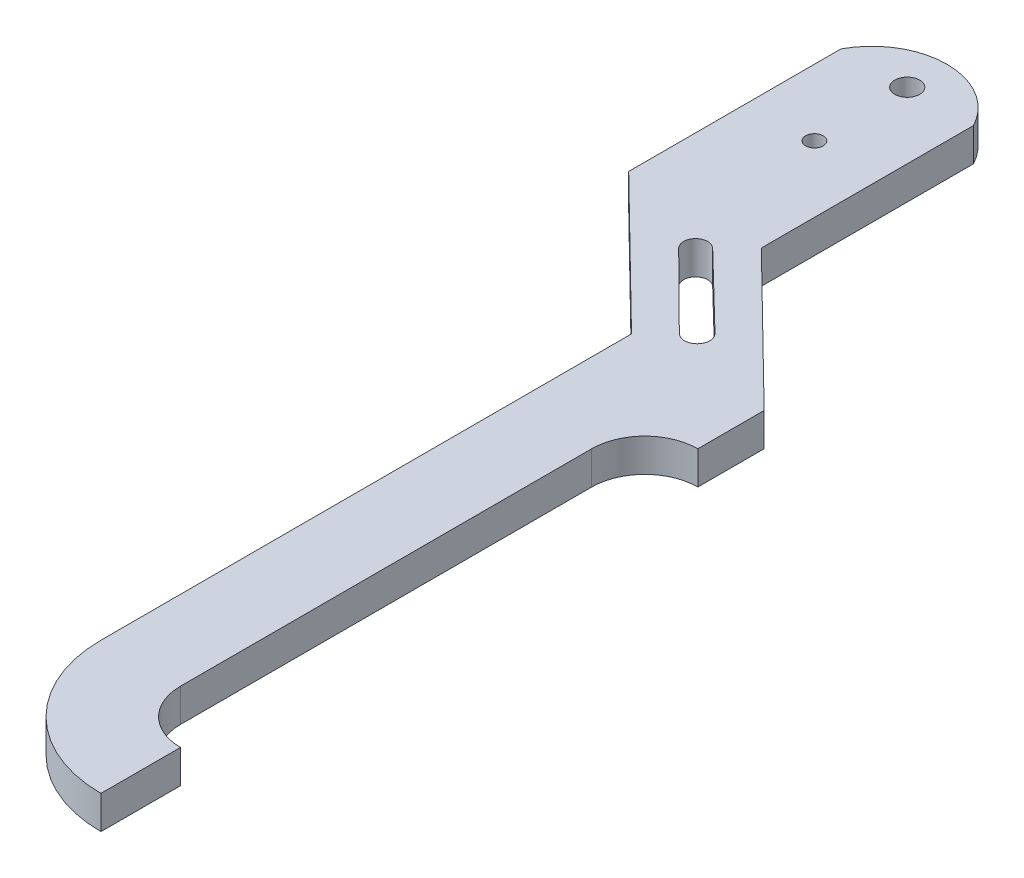
from build123d import *

# Parameters (mm, degrees)
SKETCH1_R           = 0.840105
SKETCH1_R_2         = 1.190625
BOSS_EXTRUDE1_DEPTH = 3.175


with BuildPart() as part:
    # Sketch1 → Boss-Extrude1 (new body)
    with BuildSketch(Plane(origin=(0, 0, 0), x_dir=(1, 0, 0), z_dir=(0, 1, 0))):
        with BuildLine():
            Line((-13.027020503, 16.390799837), (-13.027020503, 36.710799837))
            ThreePointArc((-13.027020503, 36.710799837), (-10.379674956, 39.495223926), (-6.677020503, 40.520799837))
            ThreePointArc((-6.677020503, 40.520799837), (-2.974366049, 39.495223926), (-0.327020503, 36.710799837))
            Line((-0.327020503, 36.710799837), (-0.327020503, 16.390799837))
            Line((-0.327020503, 16.390799837), (13.277400654, 3.055799837))
            Line((13.277400654, 3.055799837), (13.277400654, -3.294200163))
            ThreePointArc((13.277400654, -3.294200163), (9.685298205, -4.782097715), (8.197400654, -8.374200163))
            Line((8.197400654, -8.374200163), (8.197400654, -47.744200163))
            ThreePointArc((8.197400654, -47.744200163), (9.685298205, -51.336302612), (13.277400654, -52.824200163))
            Line((13.277400654, -52.824200163), (13.277400654, -60.444200163))
            ThreePointArc((13.277400654, -60.444200163), (4.297144533, -56.724456284), (0.577400654, -47.744200163))
            Line((0.577400654, -47.744200163), (0.577400654, 3.055799837))
            Line((0.577400654, 3.055799837), (-13.027020503, 16.390799837))
        make_face()
        with Locations((-6.677020503, 27.820799837)):
            Circle(SKETCH1_R, mode=Mode.SUBTRACT)
        with Locations((-6.677020503, 36.710799837)):
            Circle(SKETCH1_R_2, mode=Mode.SUBTRACT)
        with BuildLine():
            Line((-2.63294069, 14.03829086), (4.529585854, 7.097736719))
            ThreePointArc((4.529585854, 7.097736719), (4.551571997, 5.389416502), (2.843251781, 5.367430359))
            Line((2.843251781, 5.367430359), (-4.24408648, 12.394593219))
            ThreePointArc((-4.24408648, 12.394593219), (-4.260362405, 14.022014935), (-2.63294069, 14.03829086))
        make_face(mode=Mode.SUBTRACT)
    extrude(amount=BOSS_EXTRUDE1_DEPTH)


solid = part.part
